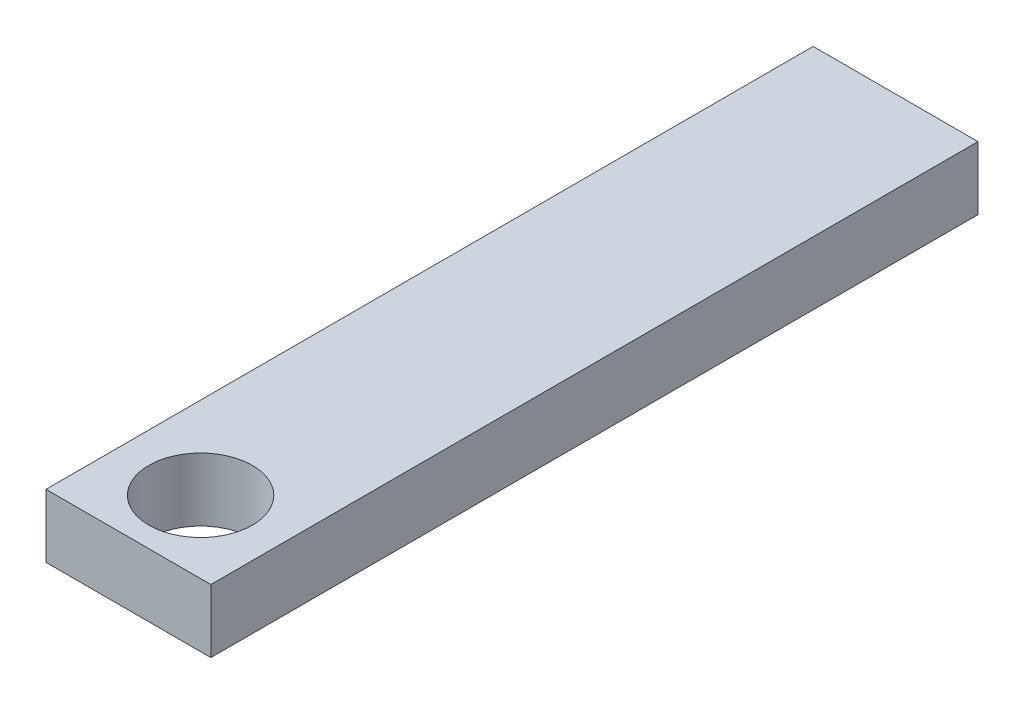
from build123d import *

# Parameters (mm, degrees)
SKETCH1_R           = 2.07899
BOSS_EXTRUDE1_DEPTH = 2.54


with BuildPart() as part:
    # Sketch1 → Boss-Extrude1 (new body)
    with BuildSketch(Plane(origin=(0, 0, 0), x_dir=(1, 0, 0), z_dir=(0, 1, 0))):
        Polygon((0, 0), (6.618, 0), (6.618, -25.450703704), (6.618, -30.796997366), (0, -30.796997366), (0, -27.9), (0, -25.450703704), align=None)
        with Locations((3.309, -27.9)):
            Circle(SKETCH1_R, mode=Mode.SUBTRACT)
    extrude(amount=BOSS_EXTRUDE1_DEPTH)


solid = part.part
